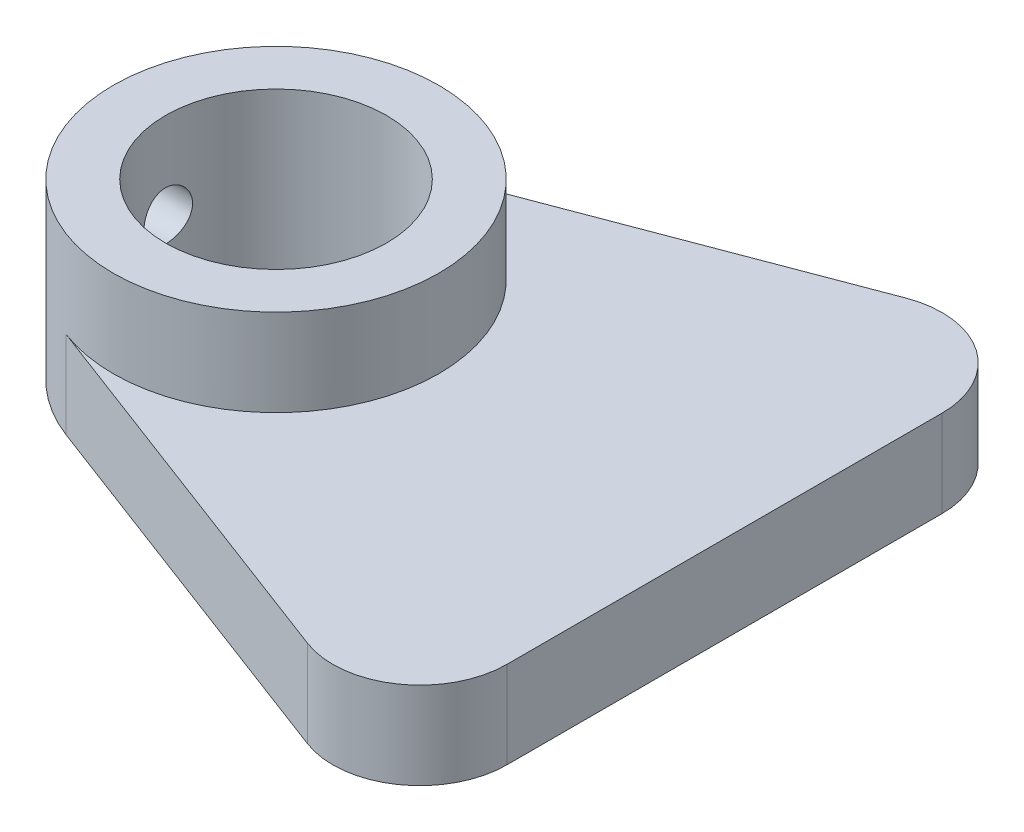
from build123d import *

# Parameters (mm, degrees)
SKETCH1_R           = 6.35
BOSS_EXTRUDE1_DEPTH = 5
SKETCH1_3_R         = 6.35
BOSS_EXTRUDE2_DEPTH = 10
SKETCH2_R           = 1.4
CUT_EXTRUDE1_DEPTH  = 33.708219151


with BuildPart() as part:
    # Sketch1 → Boss-Extrude1 (new body)
    with BuildSketch(Plane(origin=(0, 0, 0), x_dir=(1, 0, 0), z_dir=(0, 1, 0))):
        with BuildLine():
            Line((18.991661947, 17.176855838), (-3.306792159, 8.745720417))
            ThreePointArc((-3.306792159, 8.745720417), (-9.35, 0), (-3.306792159, -8.745720417))
            Line((-3.306792159, -8.745720417), (18.991661947, -17.176855838))
            ThreePointArc((18.991661947, -17.176855838), (23.602385419, -16.613495488), (25.76, -12.5))
            Line((25.76, -12.5), (25.76, 12.5))
            ThreePointArc((25.76, 12.5), (23.602385419, 16.613495488), (18.991661947, 17.176855838))
        make_face()
        Circle(SKETCH1_R, mode=Mode.SUBTRACT)
    extrude(amount=BOSS_EXTRUDE1_DEPTH)

    # Sketch1_3 → Boss-Extrude2 (add)
    with BuildSketch(Plane(origin=(0, 0, 0), x_dir=(1, 0, 0), z_dir=(0, 1, 0))):
        with BuildLine():
            ThreePointArc((9.35, 0), (5.315260733, 7.692236563), (-3.306792159, 8.745720417))
            ThreePointArc((-3.306792159, 8.745720417), (-9.35, 0), (-3.306792159, -8.745720417))
            ThreePointArc((-3.306792159, -8.745720417), (5.315260733, -7.692236563), (9.35, 0))
        make_face()
        Circle(SKETCH1_3_R, mode=Mode.SUBTRACT)
    extrude(amount=BOSS_EXTRUDE2_DEPTH)

    # Sketch2 → Cut-Extrude1 (cut, through all)
    with BuildSketch(Plane(origin=(0, 0, 0), x_dir=(0, 0, -1), z_dir=(1, 0, 0))):
        with Locations((0, 5)):
            Circle(SKETCH2_R)
    extrude(amount=-CUT_EXTRUDE1_DEPTH, mode=Mode.SUBTRACT)


solid = part.part
